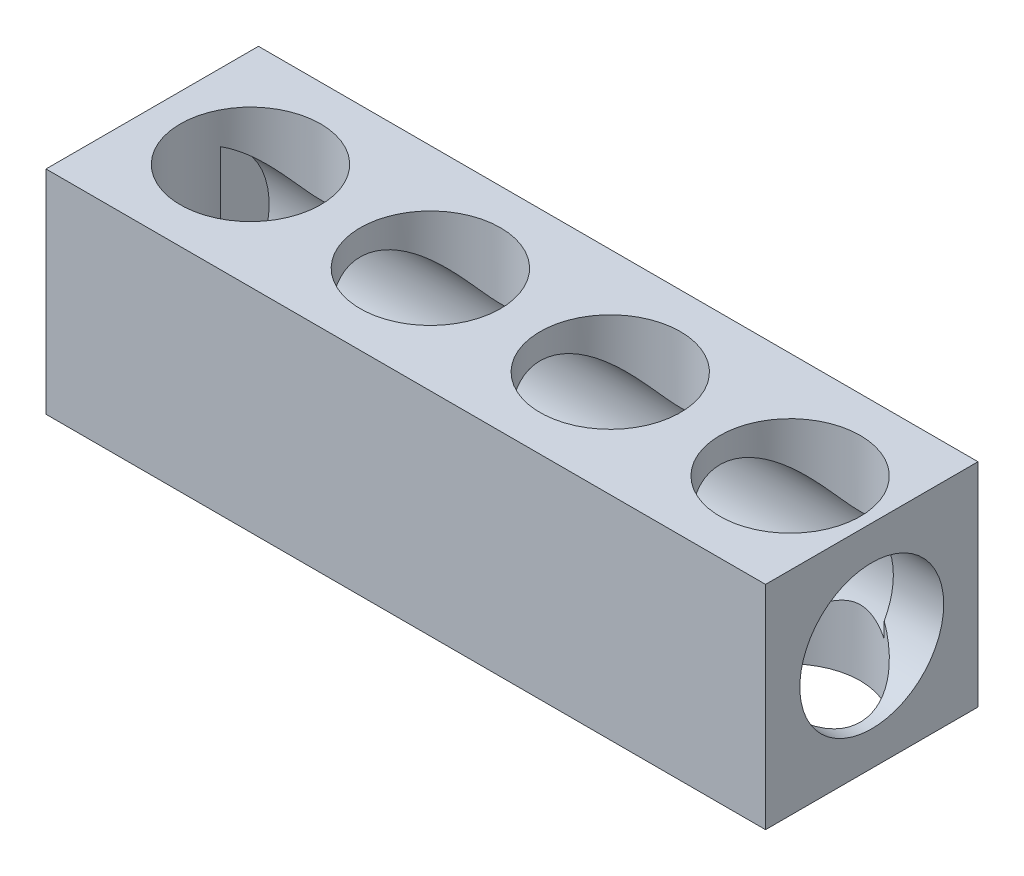
from build123d import *

# Parameters (mm, degrees)
SKETCH1_W           = 15
SKETCH1_H           = 15
BOSS_EXTRUDE1_DEPTH = 50.8
SKETCH3_R           = 5.715
CUT_EXTRUDE1_DEPTH  = 44.704
SKETCH5_R           = 4.953
CUT_EXTRUDE3_DEPTH  = 16
LPATTERN1_COUNT     = 4
LPATTERN1_PITCH     = 12.7
SKETCH4_R           = 5.08
CUT_EXTRUDE5_DEPTH  = 6.096


with BuildPart() as part:
    # Sketch1 → Boss-Extrude1 (new body)
    with BuildSketch(Plane(origin=(0, 0, 0), x_dir=(0, 0, -1), z_dir=(1, 0, 0))):
        Rectangle(SKETCH1_W, SKETCH1_H)
    extrude(amount=-BOSS_EXTRUDE1_DEPTH)

    # Sketch3 → Cut-Extrude1 (cut)
    with BuildSketch(Plane.ZY.offset(48.26)):
        Circle(SKETCH3_R)
    extrude(amount=-CUT_EXTRUDE1_DEPTH, mode=Mode.SUBTRACT)

    # Sketch5 → Cut-Extrude3 (cut, through all)
    with BuildSketch(Plane(origin=(0, -7.5, 0), x_dir=(-1, 0, 0), z_dir=(0, -1, 0))):
        with Locations((43.863365925, 0)):
            Circle(SKETCH5_R)
    cut_extrude3 = extrude(amount=-CUT_EXTRUDE3_DEPTH, mode=Mode.SUBTRACT)

    # LPattern1: Cut-Extrude3 ×4
    with Locations(*[(i * LPATTERN1_PITCH, 0, 0) for i in range(1, LPATTERN1_COUNT)]):
        add(cut_extrude3, mode=Mode.SUBTRACT)

    # Sketch4 → Cut-Extrude5 (cut)
    with BuildSketch(Plane(origin=(0, 0, 0), x_dir=(0, 0, -1), z_dir=(1, 0, 0))):
        Circle(SKETCH4_R)
    extrude(amount=-CUT_EXTRUDE5_DEPTH, mode=Mode.SUBTRACT)


solid = part.part
